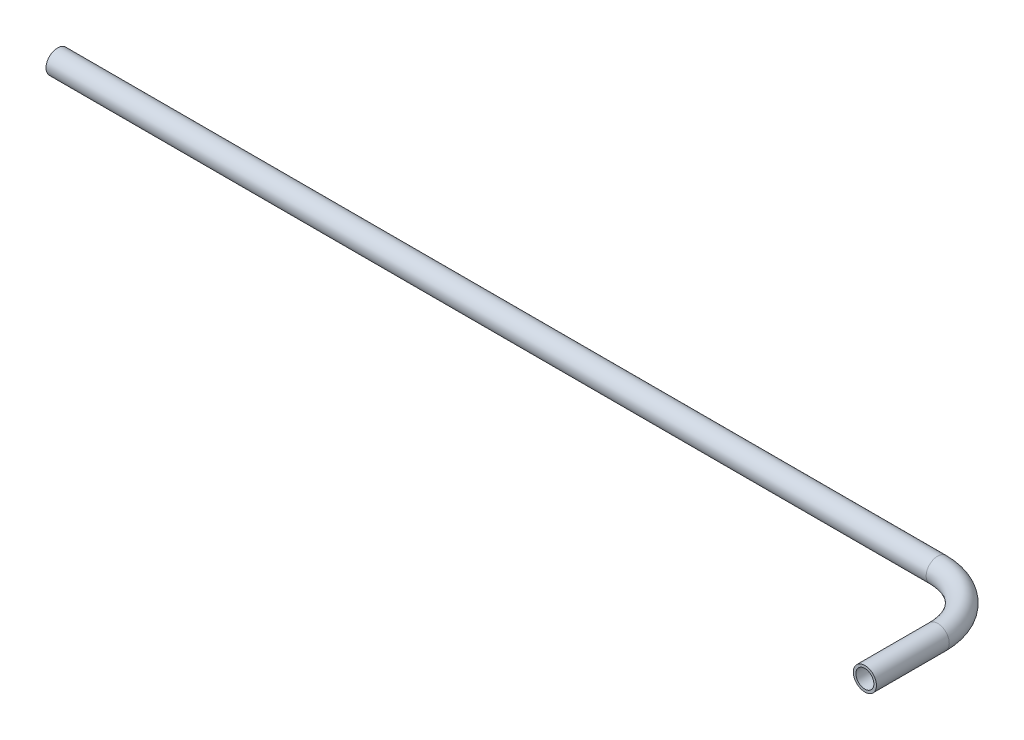
from build123d import *

# Parameters (mm, degrees)
SKETCH2_R   = 3.175
SKETCH2_R_2 = 2.4638


with BuildPart() as part:
    # Sweep-Thin1: sweep along a path in Sketch1
    with BuildLine(Plane(origin=(0, 0, 0), x_dir=(1, 0, 0), z_dir=(0, 1, 0))) as sweep_thin1_path:
        Line((-257.7, 36), (-16, 36))
        ThreePointArc((-16, 36), (-4.686291501, 31.313708499), (0, 20))
        Line((0, 20), (0, 0))
    # Sketch2 → Sweep-Thin1 (sweep)
    with BuildSketch(Plane.XY):
        Circle(SKETCH2_R)
        Circle(SKETCH2_R_2, mode=Mode.SUBTRACT)
    sweep(path=sweep_thin1_path.line)


solid = part.part
